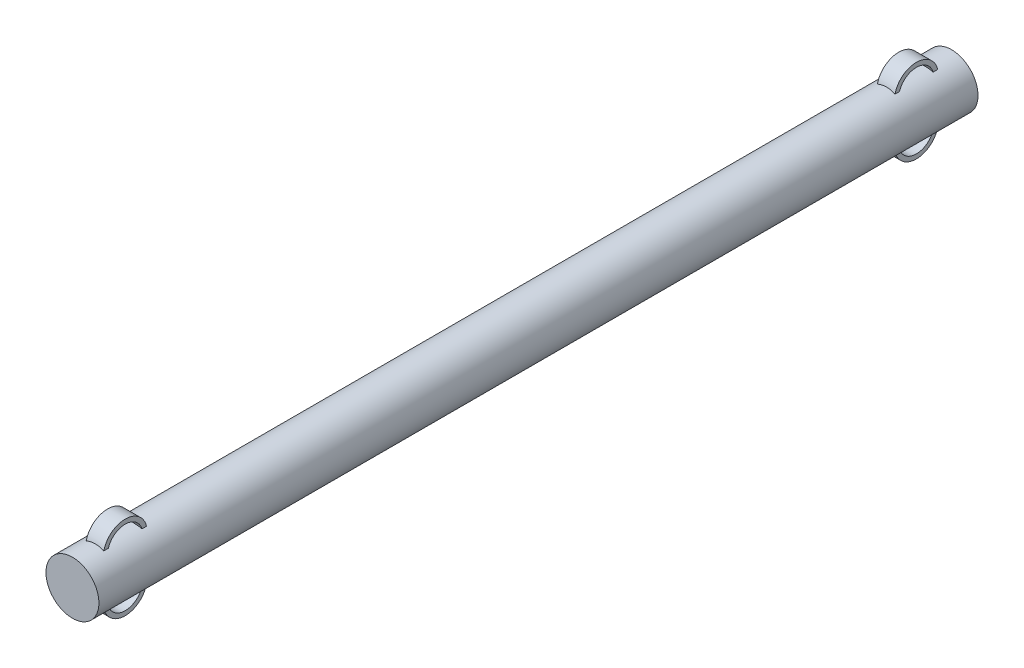
from build123d import *

# Parameters (mm, degrees)
SKETCH1_R            = 1.53035
BOSS_EXTRUDE1_DEPTH  = 50.8
BOSS_EXTRUDE2_DEPTH  = 0.508
MIRROR2_COPY_1_DEPTH = 0.508


with BuildPart() as part:
    # Sketch1 → Boss-Extrude1 (new body)
    with BuildSketch(Plane.XY):
        Circle(SKETCH1_R)
    extrude(amount=BOSS_EXTRUDE1_DEPTH)

    # Sketch2 → Boss-Extrude2 (add, symmetric)
    with BuildSketch(Plane(origin=(0, 0, 0), x_dir=(0, 0, -1), z_dir=(1, 0, 0))):
        with BuildLine():
            ThreePointArc((-46.99, 1.14935), (-48.26, 2.41935), (-49.53, 1.14935))
            Line((-49.53, 1.14935), (-49.276, 1.14935))
            ThreePointArc((-49.276, 1.14935), (-48.26, 2.16535), (-47.244, 1.14935))
            Line((-47.244, 1.14935), (-46.99, 1.14935))
        make_face()
    boss_extrude2 = extrude(amount=BOSS_EXTRUDE2_DEPTH, both=True)

    # Mirror1: Boss-Extrude2 across plane
    add(boss_extrude2.mirror(Plane.ZX))

    # Mirror2: Boss-Extrude2 across plane
    add(boss_extrude2.mirror(Plane(origin=(0, 0, 25.4), x_dir=(1, 0, 0), z_dir=(0, 0, -1))))

    # Mirror2 copy 1 sketch → Mirror2 copy 1 (add, symmetric)
    with BuildSketch(Plane(origin=(0, 0, 50.8), x_dir=(0, 0, 1), z_dir=(1, 0, 0))):
        with BuildLine():
            ThreePointArc((-46.99, 1.14935), (-48.26, 2.41935), (-49.53, 1.14935))
            Line((-49.53, 1.14935), (-49.276, 1.14935))
            ThreePointArc((-49.276, 1.14935), (-48.26, 2.16535), (-47.244, 1.14935))
            Line((-47.244, 1.14935), (-46.99, 1.14935))
        make_face()
    extrude(amount=MIRROR2_COPY_1_DEPTH, both=True)


solid = part.part
